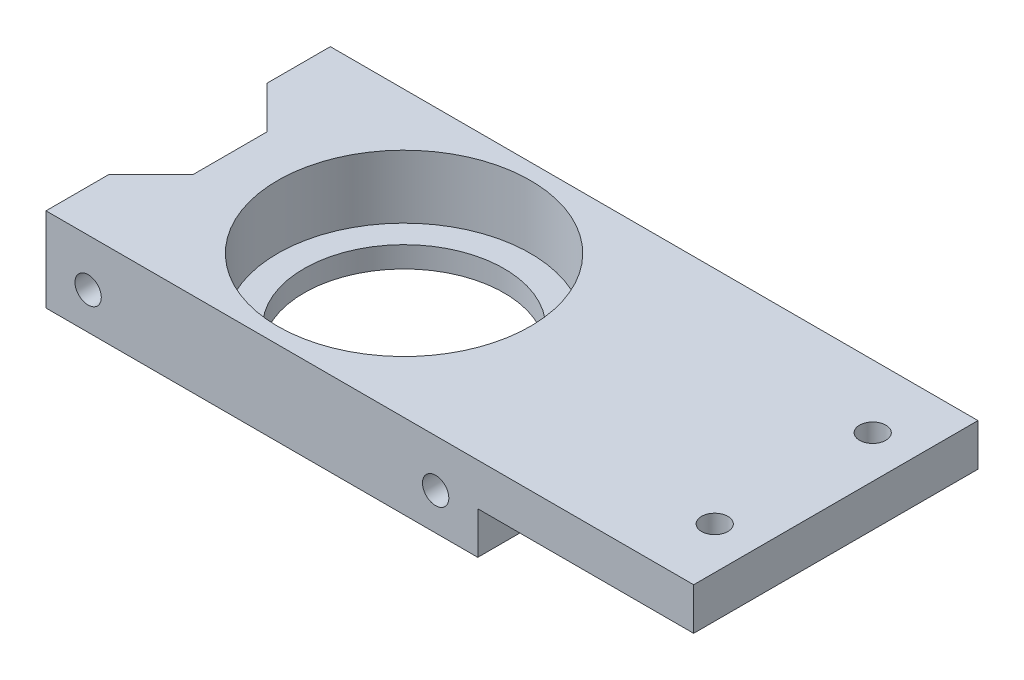
from build123d import *

# Parameters (mm, degrees)
SKETCH_1_R          = 9.5
EXTRUDE_1_DEPTH     = 8
SKETCH_1_2_R        = 9.5
EXTRUDE_2_DEPTH     = 8
SKETCH_2_R          = 12
CUT_EXTRUDE_1_DEPTH = 6
SKETCH_3_W          = 20.5
SKETCH_3_H          = 27
CUT_EXTRUDE_2_DEPTH = 4
SKETCH_4_R          = 1.25
CUT_EXTRUDE_3_DEPTH = 5
SKETCH_5_R          = 1.25
CUT_EXTRUDE_4_DEPTH = 7
SKETCH_6_R          = 1.25
CUT_EXTRUDE_5_DEPTH = 7


with BuildPart() as part:
    # Sketch 1 → Extrude 1 (new body)
    with BuildSketch(Plane(origin=(0, 0, 0), x_dir=(1, 0, 0), z_dir=(0, 1, 0))):
        Polygon((-20.5, -13.5), (-20.5, -7.5), (-16.5, -3.5), (-16.5, 3.5), (-20.5, 7.5), (-20.5, 13.5), (41, 13.5), (41, -13.5), align=None)
        with Locations(Location((0, 0, 0), (0, 0, 270))):  # turned: the seam where the file's is
            Circle(SKETCH_1_R, mode=Mode.SUBTRACT)
    extrude(amount=EXTRUDE_1_DEPTH)

    # Sketch 1_2 → Extrude 2 (add)
    with BuildSketch(Plane(origin=(0, 0, 0), x_dir=(1, 0, 0), z_dir=(0, 1, 0))):
        Polygon((-20.5, -13.5), (-20.5, -7.5), (-16.5, -3.5), (-16.5, 3.5), (-20.5, 7.5), (-20.5, 13.5), (41, 13.5), (41, -13.5), align=None)
        with Locations(Location((0, 0, 0), (0, 0, 270))):  # turned: the seam where the file's is
            Circle(SKETCH_1_2_R, mode=Mode.SUBTRACT)
    extrude(amount=EXTRUDE_2_DEPTH)

    # Sketch 2 → Cut-Extrude 1 (cut)
    with BuildSketch(Plane(origin=(0, 8, 0), x_dir=(1, 0, 0), z_dir=(0, 1, 0))):
        with Locations(Location((0, 0, 0), (0, 0, 270))):  # turned: the seam where the file's is
            Circle(SKETCH_2_R)
    extrude(amount=-CUT_EXTRUDE_1_DEPTH, mode=Mode.SUBTRACT)

    # Sketch 3 → Cut-Extrude 2 (cut)
    with BuildSketch(Plane.XZ):
        with Locations((30.75, 0)):
            Rectangle(SKETCH_3_W, SKETCH_3_H)
    extrude(amount=-CUT_EXTRUDE_2_DEPTH, mode=Mode.SUBTRACT)

    # Sketch 4 → Cut-Extrude 3 (cut, through all)
    with BuildSketch(Plane.XZ.offset(-4)):
        with Locations(Location((37, 7.5, 0), (0, 0, 270))):  # turned: the seam where the file's is
            Circle(SKETCH_4_R)
        with Locations(Location((37, -7.5, 0), (0, 0, 90))):  # turned: the seam where the file's is
            Circle(SKETCH_4_R)
    extrude(amount=-CUT_EXTRUDE_3_DEPTH, mode=Mode.SUBTRACT)

    # Sketch 5 → Cut-Extrude 4 (cut)
    with BuildSketch(Plane.XY.offset(13.5)):
        with Locations((-16.5, 3.500018951)):
            Circle(SKETCH_5_R)
        with Locations(Location((16.5, 3.500018951, 0), (0, 0, 180))):  # turned: the seam where the file's is
            Circle(SKETCH_5_R)
    extrude(amount=-CUT_EXTRUDE_4_DEPTH, mode=Mode.SUBTRACT)

    # Sketch 6 → Cut-Extrude 5 (cut)
    with BuildSketch(Plane(origin=(0, 0, -13.5), x_dir=(-1, 0, 0), z_dir=(0, 0, -1))):
        with Locations((16.5, 4)):
            Circle(SKETCH_6_R)
        with Locations(Location((-16.5, 4, 0), (0, 0, 180))):  # turned: the seam where the file's is
            Circle(SKETCH_6_R)
    extrude(amount=-CUT_EXTRUDE_5_DEPTH, mode=Mode.SUBTRACT)


solid = part.part
